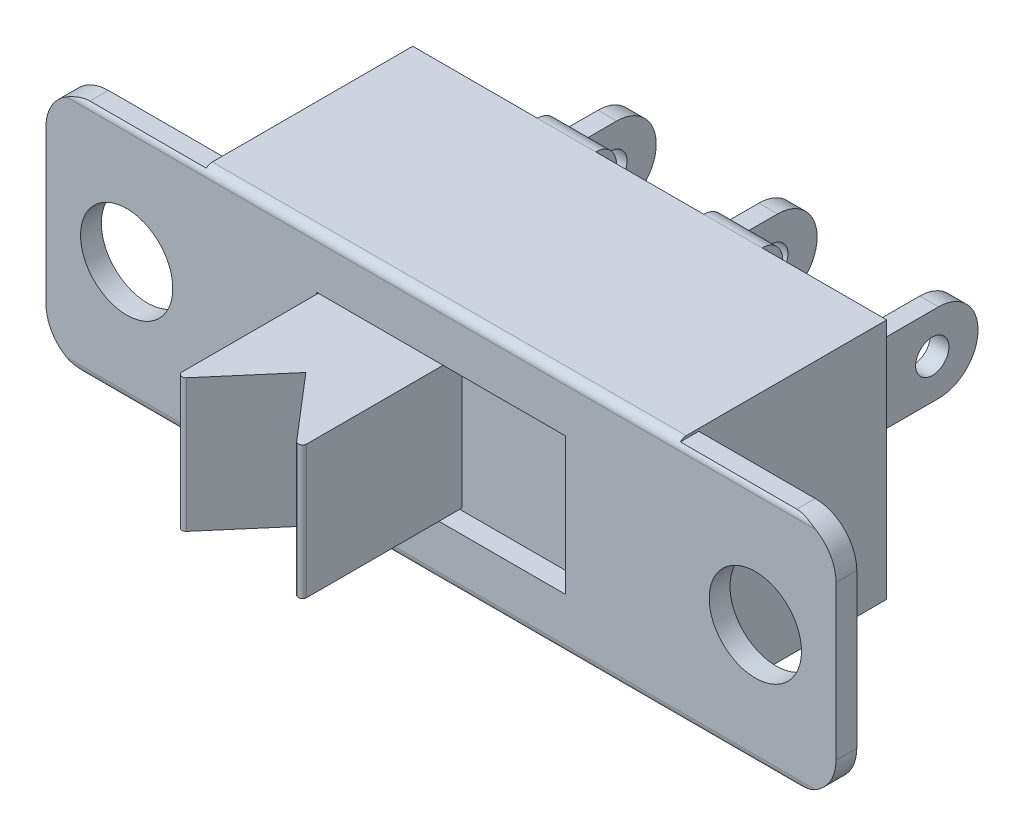
from build123d import *

# Parameters (mm, degrees)
ESQUISSE1_R             = 1.11
BASE_EXTRUSION_DEPTH    = 0.5
ESQUISSE2_W             = 11.4
ESQUISSE2_H             = 5.82
BOSS_EXTRU_1_DEPTH      = 5.02
ESQUISSE3_W             = 6
ESQUISSE3_H             = 3.3
ENL_V_MAT_EXTRU_1_DEPTH = 0.5
ESQUISSE4_W             = 3
ESQUISSE4_H             = 3.2
BOSS_EXTRU_2_DEPTH      = 4
ENL_V_MAT_EXTRU_2_DEPTH = 5.51
CONG_1_R                = 0.1
ESQUISSE6_W             = 0.45
ESQUISSE6_H             = 1.91
BOSS_EXTRU_3_DEPTH      = 3.8
CONG_2_R                = 0.95
ESQUISSE7_R             = 0.4
ENL_V_MAT_EXTRU_3_DEPTH = 14.595
ESQUISSE8_W             = 1.4
ESQUISSE8_H             = 1.4
BOSS_EXTRU_4_DEPTH      = 0.5
CONG_3_R                = 0.5
CONG_4_R                = 0.2


with BuildPart() as part:
    # Esquisse1 → Base-Extrusion (new body)
    with BuildSketch(Plane.XY):
        with BuildLine():
            Line((-8.5, 2.85), (8.5, 2.85))
            ThreePointArc((8.5, 2.85), (9.207106781, 2.557106781), (9.5, 1.85))
            Line((9.5, 1.85), (9.5, -1.85))
            ThreePointArc((9.5, -1.85), (9.207106781, -2.557106781), (8.5, -2.85))
            Line((8.5, -2.85), (-8.5, -2.85))
            ThreePointArc((-8.5, -2.85), (-9.207106781, -2.557106781), (-9.5, -1.85))
            Line((-9.5, -1.85), (-9.5, 1.85))
            ThreePointArc((-9.5, 1.85), (-9.207106781, 2.557106781), (-8.5, 2.85))
        make_face()
        with Locations((7.56, 0)):
            Circle(ESQUISSE1_R, mode=Mode.SUBTRACT)
        with Locations(Location((-7.56, 0, 0), (0, 0, 180))):  # turned: the seam where the file's is
            Circle(ESQUISSE1_R, mode=Mode.SUBTRACT)
    extrude(amount=BASE_EXTRUSION_DEPTH)

    # Esquisse2 → Boss.-Extru.1 (add)
    with BuildSketch(Plane.XY.offset(0.5)):
        Rectangle(ESQUISSE2_W, ESQUISSE2_H)
    extrude(amount=-BOSS_EXTRU_1_DEPTH)

    # Esquisse3 → Enlèv. mat.-Extru.1 (cut)
    with BuildSketch(Plane.XY.offset(0.5)):
        Rectangle(ESQUISSE3_W, ESQUISSE3_H)
    extrude(amount=-ENL_V_MAT_EXTRU_1_DEPTH, mode=Mode.SUBTRACT)

    # Esquisse4 → Boss.-Extru.2 (add)
    with BuildSketch(Plane.XY):
        with Locations((-1.5, 0)):
            Rectangle(ESQUISSE4_W, ESQUISSE4_H)
    extrude(amount=BOSS_EXTRU_2_DEPTH)

    # Esquisse5 → Enlèv. mat.-Extru.2 (cut, through all)
    with BuildSketch(Plane.XZ.offset(1.6)):
        Polygon((0, 4), (-1.5, 2.25), (-3, 4), (-3, 5.046492564), (0, 5.046492564), align=None)
    extrude(amount=-ENL_V_MAT_EXTRU_2_DEPTH, mode=Mode.SUBTRACT)

    # Congé1
    cong_1_edges = [part.edges().sort_by_distance(p)[0] for p in [
        (-3, 0, 4),
        (0, 0, 4),
    ]]
    fillet(cong_1_edges, radius=CONG_1_R)

    # Esquisse6 → Boss.-Extru.3 (add)
    with BuildSketch(Plane(origin=(0, 0, -4.52), x_dir=(-1, 0, 0), z_dir=(0, 0, -1))):
        Rectangle(ESQUISSE6_W, ESQUISSE6_H)
        with Locations((3.87, 0)):
            Rectangle(ESQUISSE6_W, ESQUISSE6_H)
        with Locations((-3.87, 0)):
            Rectangle(ESQUISSE6_W, ESQUISSE6_H)
    extrude(amount=BOSS_EXTRU_3_DEPTH)

    # Congé2
    cong_2_edges = [part.edges().sort_by_distance(p)[0] for p in [
        (3.87, 0.955, -8.32),
        (3.87, -0.955, -8.32),
        (0, -0.955, -8.32),
        (0, 0.955, -8.32),
        (-3.87, -0.955, -8.32),
        (-3.87, 0.955, -8.32),
    ]]
    fillet(cong_2_edges, radius=CONG_2_R)

    # Esquisse7 → Enlèv. mat.-Extru.3 (cut, through all)
    with BuildSketch(Plane(origin=(4.095, 0, 0), x_dir=(0, 0, -1), z_dir=(1, 0, 0))):
        with Locations((7.22, 0)):
            Circle(ESQUISSE7_R)
    extrude(amount=-ENL_V_MAT_EXTRU_3_DEPTH, mode=Mode.SUBTRACT)

    # Esquisse8 → Boss.-Extru.4 (add)
    with BuildSketch(Plane(origin=(0, 0, -4.52), x_dir=(-1, 0, 0), z_dir=(0, 0, -1))):
        with Locations((2, -2.21)):
            Rectangle(ESQUISSE8_W, ESQUISSE8_H)
        with Locations((2, 2.21)):
            Rectangle(ESQUISSE8_W, ESQUISSE8_H)
        with Locations((-2, 2.21)):
            Rectangle(ESQUISSE8_W, ESQUISSE8_H)
        with Locations((-2, -2.21)):
            Rectangle(ESQUISSE8_W, ESQUISSE8_H)
    extrude(amount=BOSS_EXTRU_4_DEPTH)

    # Congé3
    cong_3_edges = [part.edges().sort_by_distance(p)[0] for p in [
        (2, -2.91, -5.02),
        (-2, -2.91, -5.02),
        (-2, 2.91, -5.02),
        (2, 2.91, -5.02),
    ]]
    fillet(cong_3_edges, radius=CONG_3_R)

    # Congé4
    cong_4_edges = [part.edges().sort_by_distance(p)[0] for p in [
        (0, -2.91, 0.5),
        (0, 2.91, 0.5),
    ]]
    fillet(cong_4_edges, radius=CONG_4_R)


solid = part.part
